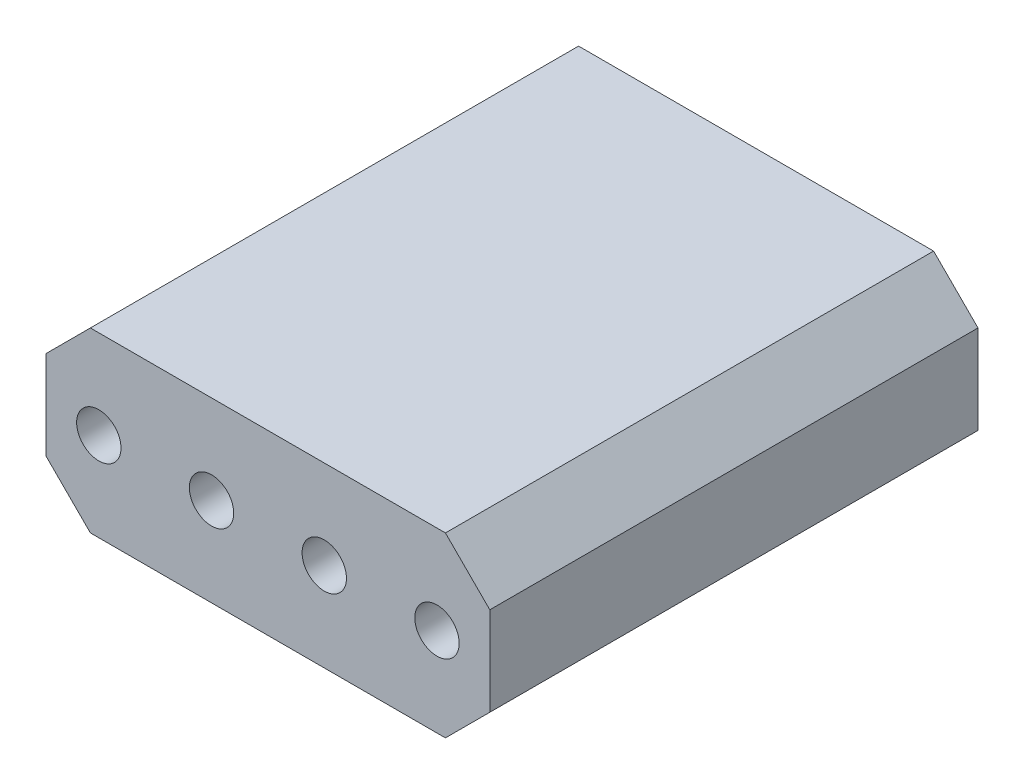
from build123d import *

# Parameters (mm, degrees)
SKETCH_5_W      = 10
SKETCH_5_H      = 4
SKETCH_5_W_2    = 0.7
SKETCH_5_H_2    = 0.7
EXTRUDE_2_DEPTH = 8
SKETCH_6_W      = 10
SKETCH_6_H      = 4
SKETCH_6_R      = 0.5
EXTRUDE_3_DEPTH = 3
CHAMFER_3_SIZE  = 1


with BuildPart() as part:
    # Эскиз5 → Бобышка-Вытянуть2 (new body)
    with BuildSketch(Plane.XY):
        Rectangle(SKETCH_5_W, SKETCH_5_H)
        with Locations((-3.81, 0)):
            Rectangle(SKETCH_5_W_2, SKETCH_5_H_2, mode=Mode.SUBTRACT)
        with Locations((3.81, 0)):
            Rectangle(SKETCH_5_W_2, SKETCH_5_H_2, mode=Mode.SUBTRACT)
        with Locations((-1.27, 0)):
            Rectangle(SKETCH_5_W_2, SKETCH_5_H_2, mode=Mode.SUBTRACT)
        with Locations((1.27, 0)):
            Rectangle(SKETCH_5_W_2, SKETCH_5_H_2, mode=Mode.SUBTRACT)
    extrude(amount=EXTRUDE_2_DEPTH)

    # Эскиз6 → Бобышка-Вытянуть3 (add)
    with BuildSketch(Plane.XY.offset(8)):
        Rectangle(SKETCH_6_W, SKETCH_6_H)
        with Locations((-3.81, 0)):
            Circle(SKETCH_6_R, mode=Mode.SUBTRACT)
        with Locations((-1.27, 0)):
            Circle(SKETCH_6_R, mode=Mode.SUBTRACT)
        with Locations((1.27, 0)):
            Circle(SKETCH_6_R, mode=Mode.SUBTRACT)
        with Locations((3.81, 0)):
            Circle(SKETCH_6_R, mode=Mode.SUBTRACT)
    extrude(amount=EXTRUDE_3_DEPTH)

    # Фаска3
    chamfer_3_edges = [part.edges().sort_by_distance(p)[0] for p in [
        (5, -2, 5.5),
        (-5, -2, 5.5),
        (-5, 2, 5.5),
        (5, 2, 5.5),
    ]]
    chamfer(chamfer_3_edges, length=CHAMFER_3_SIZE)


solid = part.part
